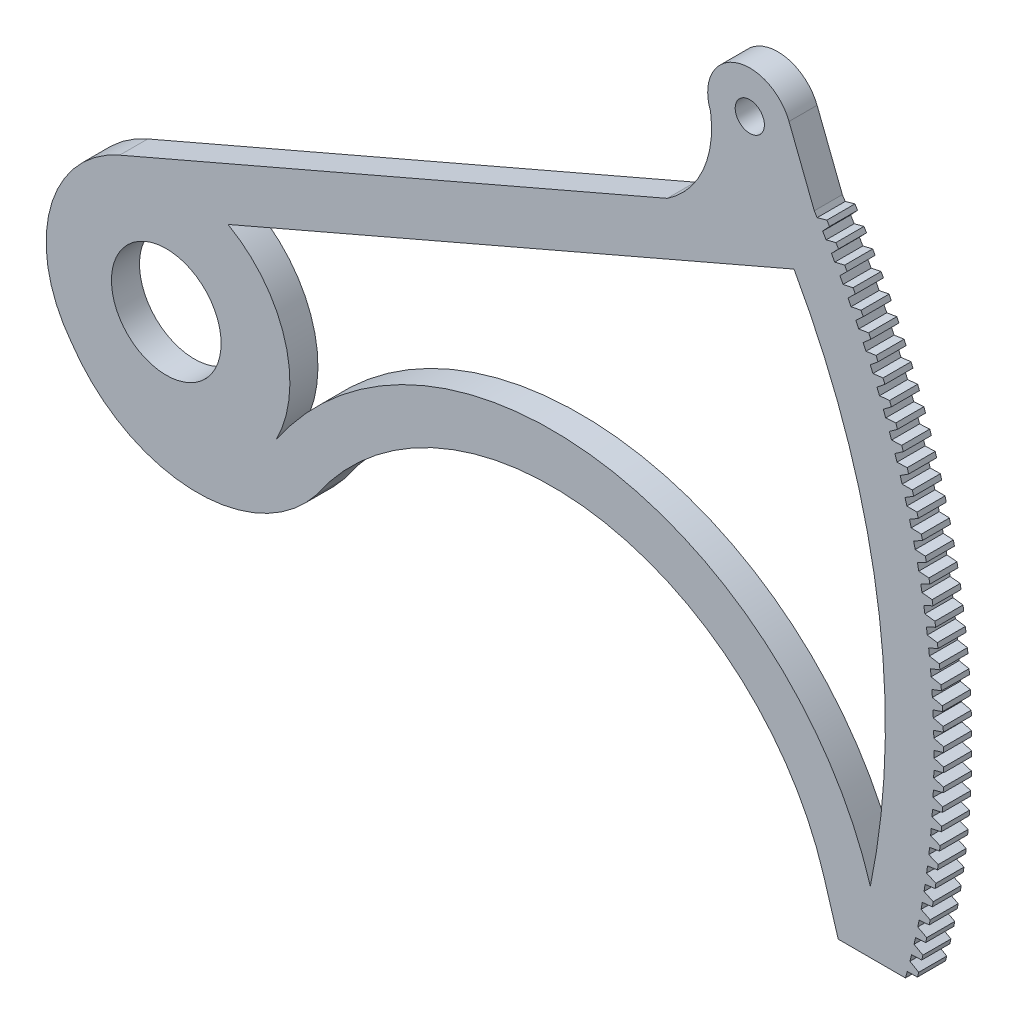
from build123d import *

# Parameters (mm, degrees)
SKETCH1_R           = 12.408212295
SKETCH1_R_2         = 3.302
BOSS_EXTRUDE1_DEPTH = 6.35


with BuildPart() as part:
    # Sketch1 → Boss-Extrude1 (new body)
    with BuildSketch(Plane.XY):
        with BuildLine():
            Line((146.633186787, 93.132961962), (140.91304048, 107.780524464))
            ThreePointArc((140.91304048, 107.780524464), (128.583573423, 113.191176173), (123.16202884, 100.866495074))
            ThreePointArc((123.16202884, 100.866495074), (121.435921865, 88.480292523), (113.354485872, 78.936296964))
            Line((113.354485872, 78.936296964), (-10.539485883, 25.458586117))
            ThreePointArc((-10.539485883, 25.458586117), (-26.30414767, 7.072892878), (-21.487058667, -16.662185184))
            ThreePointArc((-21.487058667, -16.662185184), (5.658002222, -31.885433701), (33.940593142, -18.897105216))
            ThreePointArc((33.940593142, -18.897105216), (96.785878161, 8.760995722), (148.767258454, -36.099192633))
            Line((148.767258454, -36.099192633), (152.054130393, -46.896311475))
            Line((152.054130393, -46.896311475), (167.259606723, -46.896311475))
            ThreePointArc((167.259606723, -46.896311475), (167.466164791, -46.153263388), (167.669421897, -45.409305565))
            Line((167.669421897, -45.409305565), (169.964993449, -45.370980946))
            Line((169.964993449, -45.370980946), (170.25302437, -44.27790197))
            Line((170.25302437, -44.27790197), (168.27394455, -43.115190557))
            ThreePointArc((168.27394455, -43.115190557), (168.462763368, -42.371422325), (168.648294758, -41.626827246))
            Line((168.648294758, -41.626827246), (170.942423708, -41.536883454))
            Line((170.942423708, -41.536883454), (171.20579773, -40.437602969))
            Line((171.20579773, -40.437602969), (169.20106839, -39.319696427))
            ThreePointArc((169.20106839, -39.319696427), (169.373111624, -38.571869672), (169.541849667, -37.823290216))
            Line((169.541849667, -37.823290216), (171.833375432, -37.681772753))
            Line((171.833375432, -37.681772753), (172.071959316, -36.576846877))
            Line((172.071959316, -36.576846877), (170.042594634, -35.504310746))
            ThreePointArc((170.042594634, -35.504310746), (170.19777525, -34.75280379), (170.349634582, -34.000618659))
            Line((170.349634582, -34.000618659), (172.637397896, -33.807599116))
            Line((172.637397896, -33.807599116), (172.851070943, -32.697586824))
            Line((172.851070943, -32.697586824), (170.79809756, -31.670963692))
            ThreePointArc((170.79809756, -31.670963692), (170.936337053, -30.916156716), (171.07124085, -30.160746434))
            Line((171.07124085, -30.160746434), (173.35408435, -29.916322459))
            Line((173.35408435, -29.916322459), (173.542738465, -28.801785297))
            Line((173.542738465, -28.801785297), (171.467194965, -27.821594527))
            ThreePointArc((171.467194965, -27.821594527), (171.588423401, -27.063869382), (171.706303415, -26.305616106))
            Line((171.706303415, -26.305616106), (173.983072227, -26.009911351))
            Line((173.983072227, -26.009911351), (174.146611972, -24.891413157))
            Line((174.146611972, -24.891413157), (172.049548358, -23.958150618))
            ThreePointArc((172.049548358, -23.958150618), (172.153704408, -23.197890633), (172.254501005, -22.437177957))
            Line((172.254501005, -22.437177957), (174.524043328, -22.090342018))
            Line((174.524043328, -22.090342018), (174.662385969, -20.96844863))
            Line((174.662385969, -20.96844863), (172.54486313, -20.082586455))
            ThreePointArc((172.54486313, -20.082586455), (172.631894102, -19.320176238), (172.71555629, -18.557389002))
            Line((172.71555629, -18.557389002), (174.97672398, -18.15959734))
            Line((174.97672398, -18.15959734), (175.089799529, -17.034876317))
            Line((175.089799529, -17.034876317), (172.952888705, -16.196862656))
            ThreePointArc((172.952888705, -16.196862656), (173.022750571, -15.432687906), (173.089236026, -14.668211999))
            Line((173.089236026, -14.668211999), (175.340885173, -14.219665854))
            Line((175.340885173, -14.219665854), (175.428636427, -13.092686184))
            Line((175.428636427, -13.092686184), (173.273418666, -12.302944982))
            ThreePointArc((173.273418666, -12.302944982), (173.326076083, -11.537392289), (173.37535117, -10.771614453))
            Line((173.37535117, -10.771614453), (175.616342682, -10.272540741))
            Line((175.616342682, -10.272540741), (175.678725248, -9.143872555))
            Line((175.678725248, -9.143872555), (173.506290858, -8.402803337))
            ThreePointArc((173.506290858, -8.402803337), (173.541717188, -7.636259989), (173.573756979, -6.869567626))
            Line((173.573756979, -6.869567626), (175.802957154, -6.320218825))
            Line((175.802957154, -6.320218825), (175.839939474, -5.190433107))
            Line((175.839939474, -5.190433107), (173.651387474, -4.498410775))
            ThreePointArc((173.651387474, -4.498410775), (173.669564795, -3.731264561), (173.684353082, -2.964045534))
            Line((173.684353082, -2.964045534), (175.900634184, -2.364699555))
            Line((175.900634184, -2.364699555), (175.912197548, -1.234367857))
            Line((175.912197548, -1.234367857), (173.708635111, -0.591742499))
            ThreePointArc((173.708635111, -0.591742499), (173.709554226, 0.175618488), (173.707083527, 0.942976048))
            Line((173.707083527, 0.942976048), (175.909324356, 1.592015998))
            Line((175.909324356, 1.592015998), (175.895462915, 2.722321851))
            Line((175.895462915, 2.722321851), (173.678004807, 3.315225135))
            ThreePointArc((173.678004807, 3.315225135), (173.661665251, 4.082412692), (173.641936816, 4.849520584))
            Line((173.641936816, 4.849520584), (175.829023274, 5.547926163))
            Line((175.829023274, 5.547926163), (175.78974404, 6.677634356))
            Line((175.78974404, 6.677634356), (173.559512057, 7.220515621))
            ThreePointArc((173.559512057, 7.220515621), (173.525922098, 7.987141633), (173.488945907, 8.753611783))
            Line((173.488945907, 8.753611783), (175.659771562, 9.501029672))
            Line((175.659771562, 9.501029672), (175.595094406, 10.629568694))
            Line((175.595094406, 10.629568694), (173.353216807, 11.1221533))
            ThreePointArc((173.353216807, 11.1221533), (173.302393436, 11.887829937), (173.248188196, 12.653274593))
            Line((173.248188196, 12.653274593), (175.401654844, 13.449326678))
            Line((175.401654844, 13.449326678), (175.311612486, 14.57612561))
            Line((175.311612486, 14.57612561), (173.059223419, 15.018164362))
            ThreePointArc((173.059223419, 15.018164362), (172.991192348, 15.782504275), (172.919785481, 16.546536203))
            Line((172.919785481, 16.546536203), (175.054803699, 17.390819768))
            Line((175.054803699, 17.390819768), (174.93944169, 18.51530857))
            Line((174.93944169, 18.51530857), (172.677680624, 18.906577843))
            ThreePointArc((172.677680624, 18.906577843), (172.592476269, 19.669194357), (172.503903899, 20.431427041))
            Line((172.503903899, 20.431427041), (174.619393595, 21.323514968))
            Line((174.619393595, 21.323514968), (174.478770297, 22.445124769))
            Line((174.478770297, 22.445124769), (172.208781439, 22.785426624))
            ThreePointArc((172.208781439, 22.785426624), (172.106446905, 23.545933936), (172.00075384, 24.305981767))
            Line((172.00075384, 24.305981767), (174.095644805, 25.245422756))
            Line((174.095644805, 25.245422756), (173.929831357, 26.363586142))
            Line((173.929831357, 26.363586142), (171.652763079, 26.652748422))
            ThreePointArc((171.652763079, 26.652748422), (171.533350136, 27.410761798), (171.410589846, 28.168240273))
            Line((171.410589846, 28.168240273), (173.483822288, 29.154559067))
            Line((173.483822288, 29.154559067), (173.292902575, 30.268710368))
            Line((173.292902575, 30.268710368), (171.009906829, 30.506586788))
            ThreePointArc((171.009906829, 30.506586788), (170.873475887, 31.261722754), (170.733710474, 32.01624867))
            Line((170.733710474, 32.01624867), (172.784235562, 33.048946298))
            Line((172.784235562, 33.048946298), (172.568306168, 34.158521873))
            Line((172.568306168, 34.158521873), (170.280537906, 34.344992093))
            ThreePointArc((170.280537906, 34.344992093), (170.127157984, 35.096868631), (169.970458155, 35.848060279))
            Line((169.970458155, 35.848060279), (171.997238542, 36.926614306))
            Line((171.997238542, 36.926614306), (171.756408704, 38.031052828))
            Line((171.756408704, 38.031052828), (169.46502529, 38.166022515))
            ThreePointArc((169.46502529, 38.166022515), (169.294773983, 38.914259256), (169.121219012, 39.661736614))
            Line((169.121219012, 39.661736614), (171.123229364, 40.785601408))
            Line((171.123229364, 40.785601408), (170.857620917, 41.884344149))
            Line((170.857620917, 41.884344149), (168.563781546, 41.967745022))
            ThreePointArc((168.563781546, 41.967745022), (168.376744981, 42.711963439), (168.186422668, 43.455348363))
            Line((168.186422668, 43.455348363), (170.162650183, 44.623955369))
            Line((170.162650183, 44.623955369), (169.872397496, 45.716446484))
            Line((169.872397496, 45.716446484), (167.577262605, 45.748236351))
            ThreePointArc((167.577262605, 45.748236351), (167.373535404, 46.488059949), (167.166542031, 47.226976367))
            Line((167.166542031, 47.226976367), (169.11598695, 48.439734394))
            Line((169.11598695, 48.439734394), (168.801236859, 49.525421199))
            Line((168.801236859, 49.525421199), (166.50596754, 49.505583978))
            ThreePointArc((166.50596754, 49.505583978), (166.285652766, 50.240638486), (166.06209305, 50.974712584))
            Line((166.06209305, 50.974712584), (167.983769163, 52.231008108))
            Line((167.983769163, 52.231008108), (167.644680899, 53.309341363))
            Line((167.644680899, 53.309341363), (165.350438311, 53.237887089))
            ThreePointArc((165.350438311, 53.237887089), (165.113647421, 53.967800647), (164.873634459, 54.696661064))
            Line((164.873634459, 54.696661064), (166.766569603, 55.995858533))
            Line((166.766569603, 55.995858533), (166.403314708, 57.066292716))
            Line((166.403314708, 57.066292716), (164.111259493, 56.943257538))
            ThreePointArc((164.111259493, 56.943257538), (163.858112277, 57.667660889), (163.60176749, 58.390938899))
            Line((163.60176749, 58.390938899), (165.465004044, 59.732381059))
            Line((165.465004044, 59.732381059), (165.077766285, 60.794374646))
            Line((165.077766285, 60.794374646), (162.789057976, 60.619820805))
            ThreePointArc((162.789057976, 60.619820805), (162.5196825, 61.338347479), (162.247135571, 62.055677181))
            Line((162.247135571, 62.055677181), (164.079730936, 63.438685406))
            Line((164.079730936, 63.438685406), (163.668706215, 64.491701141))
            Line((163.668706215, 64.491701141), (161.384502654, 64.265716944))
            ThreePointArc((161.384502654, 64.265716944), (161.099035192, 64.978003443), (160.810424001, 65.689021944))
            Line((160.810424001, 65.689021944), (162.611451081, 67.112896581))
            Line((162.611451081, 67.112896581), (162.176847332, 68.156401751))
            Line((162.176847332, 68.156401751), (159.898304081, 67.879101522))
            ThreePointArc((159.898304081, 67.879101522), (159.596889049, 68.584787506), (159.292359601, 69.289135108))
            Line((159.292359601, 69.289135108), (161.06090727, 70.753155828))
            Line((161.06090727, 70.753155828), (160.602944356, 71.786622532))
            Line((160.602944356, 71.786622532), (158.331214113, 71.458146554))
            ThreePointArc((158.331214113, 71.458146554), (158.014003995, 72.156875021), (157.69371035, 72.854195399))
            Line((157.69371035, 72.854195399), (159.428883912, 74.357621565))
            Line((159.428883912, 74.357621565), (158.947793513, 75.380526979))
            Line((158.947793513, 75.380526979), (156.68402553, 75.001041427))
            ThreePointArc((156.68402553, 75.001041427), (156.3511808, 75.692458895), (156.015284993, 76.38239928))
            Line((156.015284993, 76.38239928), (157.716206636, 77.92447032))
            Line((157.716206636, 77.92447032), (157.212232131, 78.936296964))
            Line((157.212232131, 78.936296964), (154.957571632, 78.505993816))
            ThreePointArc((154.957571632, 78.505993816), (154.609260676, 79.189750502), (154.257932633, 79.871961859))
            Line((154.257932633, 79.871961859), (155.923741872, 81.451897649))
            Line((155.923741872, 81.451897649), (155.39713822, 82.452133648))
            Line((155.39713822, 82.452133648), (153.152725822, 81.971230591))
            ThreePointArc((153.152725822, 81.971230591), (152.789124845, 82.646980588), (152.422542301, 83.32111779))
            Line((152.422542301, 83.32111779), (154.052396417, 84.938119053))
            Line((154.052396417, 84.938119053), (153.503430022, 85.926258394))
            Line((153.503430022, 85.926258394), (151.270401156, 85.394998714))
            ThreePointArc((151.270401156, 85.394998714), (150.891694102, 86.062400165), (150.510042508, 86.728122171))
            Line((150.510042508, 86.728122171), (152.10311697, 88.381370878))
            Line((152.10311697, 88.381370878), (151.53206555, 89.356913668))
            Line((151.53206555, 89.356913668), (149.311549889, 88.775566126))
            ThreePointArc((149.311549889, 88.775566126), (148.917928344, 89.434281397), (148.521400775, 90.091251423))
            Line((148.521400775, 90.091251423), (150.076889657, 91.779911207))
            Line((150.076889657, 91.779911207), (149.484042103, 92.742363927))
            Line((149.484042103, 92.742363927), (147.27716299, 92.111222621))
            ThreePointArc((147.27716299, 92.111222621), (146.956062871, 92.622651964), (146.633186787, 93.132961962))
        make_face()
        Circle(SKETCH1_R, mode=Mode.SUBTRACT)
        with Locations((132.040589467, 104.315666888)):
            Circle(SKETCH1_R_2, mode=Mode.SUBTRACT)
        with BuildLine():
            Line((142.041347589, 79.412448473), (13.981610582, 24.136622782))
            ThreePointArc((13.981610582, 24.136622782), (26.860070669, 7.893841022), (24.78957164, -12.731282669))
            ThreePointArc((24.78957164, -12.731282669), (98.420693279, 19.673646259), (159.323390025, -32.88568233))
            ThreePointArc((159.323390025, -32.88568233), (160.828595467, 24.824829539), (142.041347589, 79.412448473))
        make_face(mode=Mode.SUBTRACT)
    extrude(amount=BOSS_EXTRUDE1_DEPTH)


solid = part.part
